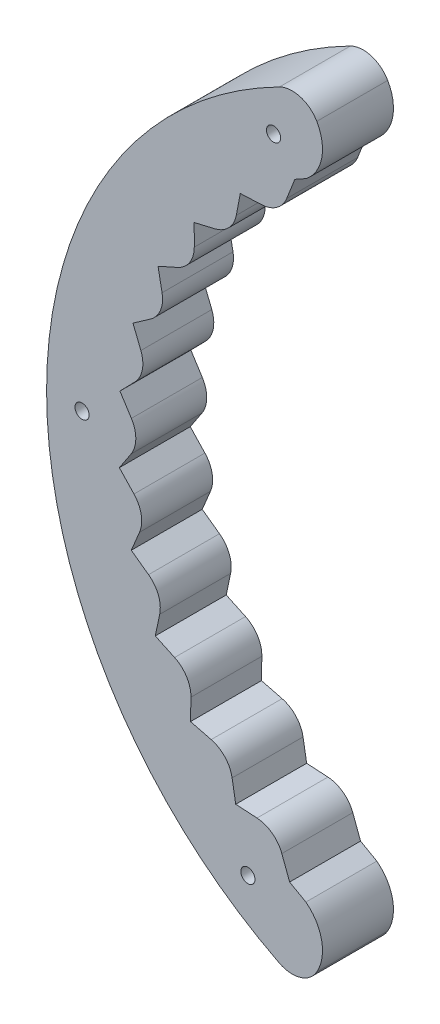
from build123d import *

# Parameters (mm, degrees)
SKETCH_1_R        = 1
EXTRUDE_1_DEPTH   = 1
SKETCH_1_2_R      = 1
EXTRUDE_1_2_DEPTH = 8
SKETCH_1_3_R      = 1
EXTRUDE_2_DEPTH   = 10
SCALE_4_SCALE     = 1.5


with BuildPart() as part:
    # 草图1 → Extrude 1 (new body)
    with BuildSketch(Plane.XY):
        with BuildLine():
            Line((-23.446136356, -44.161959762), (-25.73775467, -42.866863479))
            Line((-25.73775467, -42.866863479), (-26.834295942, -39.938466016))
            ThreePointArc((-26.834295942, -39.938466016), (-28.201527977, -38.125336415), (-30.335428898, -37.348658075))
            Line((-30.335428898, -37.348658075), (-33.334907776, -37.164700371))
            Line((-33.334907776, -37.164700371), (-33.842709051, -34.202800331))
            ThreePointArc((-33.842709051, -34.202800331), (-34.84597704, -32.165592505), (-36.7965457, -31.002818113))
            Line((-36.7965457, -31.002818113), (-39.708425324, -30.260072511))
            Line((-39.708425324, -30.260072511), (-39.652227319, -27.255483394))
            ThreePointArc((-39.652227319, -27.255483394), (-40.255989993, -25.066366444), (-41.954126526, -23.558687864))
            Line((-41.954126526, -23.558687864), (-44.675252109, -22.283466496))
            Line((-44.675252109, -22.283466496), (-44.057045667, -19.342627369))
            ThreePointArc((-44.057045667, -19.342627369), (-44.239914432, -17.079151855), (-45.625461503, -15.279979352))
            Line((-45.625461503, -15.279979352), (-48.059435816, -13.517457571))
            Line((-48.059435816, -13.517457571), (-46.901121207, -10.744549126))
            ThreePointArc((-46.901121207, -10.744549126), (-46.656617846, -8.486899797), (-47.680491761, -6.459969953))
            Line((-47.680491761, -6.459969953), (-49.741090048, -4.272585973))
            Line((-49.741090048, -4.272585973), (-48.083701146, -1.765839874))
            ThreePointArc((-48.083701146, -1.765839874), (-47.420487313, 0.406004917), (-48.046416828, 2.588887101))
            Line((-48.046416828, 2.588887101), (-49.660641368, 5.123644113))
            Line((-49.660641368, 5.123644113), (-47.562892001, 7.275425136))
            ThreePointArc((-47.562892001, 7.275425136), (-46.504462376, 9.284526705), (-46.710273625, 11.546031539))
            Line((-46.710273625, 11.546031539), (-47.82093971, 14.338366552))
            Line((-47.82093971, 14.338366552), (-45.357143694, 16.058954583))
            ThreePointArc((-45.357143694, 16.058954583), (-43.940993675, 17.834139505), (-43.719395692, 20.094152054))
            Line((-43.719395692, 20.094152054), (-44.287157421, 23.045145208))
            Line((-44.287157421, 23.045145208), (-41.54459596, 24.273587558))
            ThreePointArc((-41.54459596, 24.273587558), (-39.820893366, 25.751969023), (-39.17973637, 27.930427214))
            Line((-39.17973637, 27.930427214), (-39.184480502, 30.935538106))
            Line((-39.184480502, 30.935538106), (-36.260310201, 31.628316593))
            ThreePointArc((-36.260310201, 31.628316593), (-34.290118058, 32.757522199), (-33.252115355, 34.777253066))
            Line((-33.252115355, 34.777253066), (-32.693673826, 37.730024144))
            Line((-32.693673826, 37.730024144), (-29.691484877, 37.862596744))
            ThreePointArc((-29.691484877, 37.862596744), (-27.544598222, 38.602623821), (-26.146521576, 40.39207739))
            Line((-26.146521576, 40.39207739), (-25, 43.301270189))
            ThreePointArc((-25, 43.301270189), (-24.226890609, 43.73851588), (-23.446136356, 44.161959762))
            ThreePointArc((-23.446136356, 44.161959762), (-21.212806241, 47.755648425), (-21.906244367, 51.929556087))
            ThreePointArc((-21.906244367, 51.929556087), (-24.232021318, 53.76021953), (-27.179564099, 53.490852446))
            ThreePointArc((-27.179564099, 53.490852446), (-59.999999835, 0.004450967), (-27.1875, -53.486819346))
            Line((-27.1875, -53.486819346), (-27.179564099, -53.490852446))
            ThreePointArc((-27.179564099, -53.490852446), (-24.232021318, -53.76021953), (-21.906244367, -51.929556087))
            ThreePointArc((-21.906244367, -51.929556087), (-21.212806241, -47.755648425), (-23.446136356, -44.161959762))
        make_face()
        with Locations((-31.620079453, -45.001895242)):
            Circle(SKETCH_1_R, mode=Mode.SUBTRACT)
        with Locations((-55, 0)):
            Circle(SKETCH_1_R, mode=Mode.SUBTRACT)
        with Locations((-28.000624989, 47.338831842)):
            Circle(SKETCH_1_R, mode=Mode.SUBTRACT)
    extrude(amount=EXTRUDE_1_DEPTH)

    # 草图1<2> → Extrude 1 2 (add)
    with BuildSketch(Plane.XY):
        with BuildLine():
            Line((-23.446136356, -44.161959762), (-25.73775467, -42.866863479))
            Line((-25.73775467, -42.866863479), (-26.834295942, -39.938466016))
            ThreePointArc((-26.834295942, -39.938466016), (-28.201527977, -38.125336415), (-30.335428898, -37.348658075))
            Line((-30.335428898, -37.348658075), (-33.334907776, -37.164700371))
            Line((-33.334907776, -37.164700371), (-33.842709051, -34.202800331))
            ThreePointArc((-33.842709051, -34.202800331), (-34.84597704, -32.165592505), (-36.7965457, -31.002818113))
            Line((-36.7965457, -31.002818113), (-39.708425324, -30.260072511))
            Line((-39.708425324, -30.260072511), (-39.652227319, -27.255483394))
            ThreePointArc((-39.652227319, -27.255483394), (-40.255989993, -25.066366444), (-41.954126526, -23.558687864))
            Line((-41.954126526, -23.558687864), (-44.675252109, -22.283466496))
            Line((-44.675252109, -22.283466496), (-44.057045667, -19.342627369))
            ThreePointArc((-44.057045667, -19.342627369), (-44.239914432, -17.079151855), (-45.625461503, -15.279979352))
            Line((-45.625461503, -15.279979352), (-48.059435816, -13.517457571))
            Line((-48.059435816, -13.517457571), (-46.901121207, -10.744549126))
            ThreePointArc((-46.901121207, -10.744549126), (-46.656617846, -8.486899797), (-47.680491761, -6.459969953))
            Line((-47.680491761, -6.459969953), (-49.741090048, -4.272585973))
            Line((-49.741090048, -4.272585973), (-48.083701146, -1.765839874))
            ThreePointArc((-48.083701146, -1.765839874), (-47.420487313, 0.406004917), (-48.046416828, 2.588887101))
            Line((-48.046416828, 2.588887101), (-49.660641368, 5.123644113))
            Line((-49.660641368, 5.123644113), (-47.562892001, 7.275425136))
            ThreePointArc((-47.562892001, 7.275425136), (-46.504462376, 9.284526705), (-46.710273625, 11.546031539))
            Line((-46.710273625, 11.546031539), (-47.82093971, 14.338366552))
            Line((-47.82093971, 14.338366552), (-45.357143694, 16.058954583))
            ThreePointArc((-45.357143694, 16.058954583), (-43.940993675, 17.834139505), (-43.719395692, 20.094152054))
            Line((-43.719395692, 20.094152054), (-44.287157421, 23.045145208))
            Line((-44.287157421, 23.045145208), (-41.54459596, 24.273587558))
            ThreePointArc((-41.54459596, 24.273587558), (-39.820893366, 25.751969023), (-39.17973637, 27.930427214))
            Line((-39.17973637, 27.930427214), (-39.184480502, 30.935538106))
            Line((-39.184480502, 30.935538106), (-36.260310201, 31.628316593))
            ThreePointArc((-36.260310201, 31.628316593), (-34.290118058, 32.757522199), (-33.252115355, 34.777253066))
            Line((-33.252115355, 34.777253066), (-32.693673826, 37.730024144))
            Line((-32.693673826, 37.730024144), (-29.691484877, 37.862596744))
            ThreePointArc((-29.691484877, 37.862596744), (-27.544598222, 38.602623821), (-26.146521576, 40.39207739))
            Line((-26.146521576, 40.39207739), (-25, 43.301270189))
            ThreePointArc((-25, 43.301270189), (-24.226890609, 43.73851588), (-23.446136356, 44.161959762))
            ThreePointArc((-23.446136356, 44.161959762), (-21.212806241, 47.755648425), (-21.906244367, 51.929556087))
            ThreePointArc((-21.906244367, 51.929556087), (-24.232021318, 53.76021953), (-27.179564099, 53.490852446))
            ThreePointArc((-27.179564099, 53.490852446), (-59.999999835, 0.004450967), (-27.1875, -53.486819346))
            Line((-27.1875, -53.486819346), (-27.179564099, -53.490852446))
            ThreePointArc((-27.179564099, -53.490852446), (-24.232021318, -53.76021953), (-21.906244367, -51.929556087))
            ThreePointArc((-21.906244367, -51.929556087), (-21.212806241, -47.755648425), (-23.446136356, -44.161959762))
        make_face()
        with Locations((-31.620079453, -45.001895242)):
            Circle(SKETCH_1_2_R, mode=Mode.SUBTRACT)
        with Locations((-55, 0)):
            Circle(SKETCH_1_2_R, mode=Mode.SUBTRACT)
        with Locations((-28.000624989, 47.338831842)):
            Circle(SKETCH_1_2_R, mode=Mode.SUBTRACT)
    extrude(amount=EXTRUDE_1_2_DEPTH)

    # 草图1<3> → 凸台-拉伸2 (add)
    with BuildSketch(Plane.XY):
        with BuildLine():
            Line((-23.446136356, -44.161959762), (-25.73775467, -42.866863479))
            Line((-25.73775467, -42.866863479), (-26.834295942, -39.938466016))
            ThreePointArc((-26.834295942, -39.938466016), (-28.201527977, -38.125336415), (-30.335428898, -37.348658075))
            Line((-30.335428898, -37.348658075), (-33.334907776, -37.164700371))
            Line((-33.334907776, -37.164700371), (-33.842709051, -34.202800331))
            ThreePointArc((-33.842709051, -34.202800331), (-34.84597704, -32.165592505), (-36.7965457, -31.002818113))
            Line((-36.7965457, -31.002818113), (-39.708425324, -30.260072511))
            Line((-39.708425324, -30.260072511), (-39.652227319, -27.255483394))
            ThreePointArc((-39.652227319, -27.255483394), (-40.255989993, -25.066366444), (-41.954126526, -23.558687864))
            Line((-41.954126526, -23.558687864), (-44.675252109, -22.283466496))
            Line((-44.675252109, -22.283466496), (-44.057045667, -19.342627369))
            ThreePointArc((-44.057045667, -19.342627369), (-44.239914432, -17.079151855), (-45.625461503, -15.279979352))
            Line((-45.625461503, -15.279979352), (-48.059435816, -13.517457571))
            Line((-48.059435816, -13.517457571), (-46.901121207, -10.744549126))
            ThreePointArc((-46.901121207, -10.744549126), (-46.656617846, -8.486899797), (-47.680491761, -6.459969953))
            Line((-47.680491761, -6.459969953), (-49.741090048, -4.272585973))
            Line((-49.741090048, -4.272585973), (-48.083701146, -1.765839874))
            ThreePointArc((-48.083701146, -1.765839874), (-47.420487313, 0.406004917), (-48.046416828, 2.588887101))
            Line((-48.046416828, 2.588887101), (-49.660641368, 5.123644113))
            Line((-49.660641368, 5.123644113), (-47.562892001, 7.275425136))
            ThreePointArc((-47.562892001, 7.275425136), (-46.504462376, 9.284526705), (-46.710273625, 11.546031539))
            Line((-46.710273625, 11.546031539), (-47.82093971, 14.338366552))
            Line((-47.82093971, 14.338366552), (-45.357143694, 16.058954583))
            ThreePointArc((-45.357143694, 16.058954583), (-43.940993675, 17.834139505), (-43.719395692, 20.094152054))
            Line((-43.719395692, 20.094152054), (-44.287157421, 23.045145208))
            Line((-44.287157421, 23.045145208), (-41.54459596, 24.273587558))
            ThreePointArc((-41.54459596, 24.273587558), (-39.820893366, 25.751969023), (-39.17973637, 27.930427214))
            Line((-39.17973637, 27.930427214), (-39.184480502, 30.935538106))
            Line((-39.184480502, 30.935538106), (-36.260310201, 31.628316593))
            ThreePointArc((-36.260310201, 31.628316593), (-34.290118058, 32.757522199), (-33.252115355, 34.777253066))
            Line((-33.252115355, 34.777253066), (-32.693673826, 37.730024144))
            Line((-32.693673826, 37.730024144), (-29.691484877, 37.862596744))
            ThreePointArc((-29.691484877, 37.862596744), (-27.544598222, 38.602623821), (-26.146521576, 40.39207739))
            Line((-26.146521576, 40.39207739), (-25, 43.301270189))
            ThreePointArc((-25, 43.301270189), (-24.226890609, 43.73851588), (-23.446136356, 44.161959762))
            ThreePointArc((-23.446136356, 44.161959762), (-21.212806241, 47.755648425), (-21.906244367, 51.929556087))
            ThreePointArc((-21.906244367, 51.929556087), (-24.232021318, 53.76021953), (-27.179564099, 53.490852446))
            ThreePointArc((-27.179564099, 53.490852446), (-59.999999835, 0.004450967), (-27.1875, -53.486819346))
            Line((-27.1875, -53.486819346), (-27.179564099, -53.490852446))
            ThreePointArc((-27.179564099, -53.490852446), (-24.232021318, -53.76021953), (-21.906244367, -51.929556087))
            ThreePointArc((-21.906244367, -51.929556087), (-21.212806241, -47.755648425), (-23.446136356, -44.161959762))
        make_face()
        with Locations((-31.620079453, -45.001895242)):
            Circle(SKETCH_1_3_R, mode=Mode.SUBTRACT)
        with Locations((-55, 0)):
            Circle(SKETCH_1_3_R, mode=Mode.SUBTRACT)
        with Locations((-28.000624989, 47.338831842)):
            Circle(SKETCH_1_3_R, mode=Mode.SUBTRACT)
    extrude(amount=EXTRUDE_2_DEPTH)


with BuildPart() as part_1:
    # 缩放比例4: scaled about (-43.37819964, 0.034879878, 5)
    add(part.part.scale(SCALE_4_SCALE).moved(Location((21.68909982, -0.017439939, -2.5))))


solid = part_1.part
